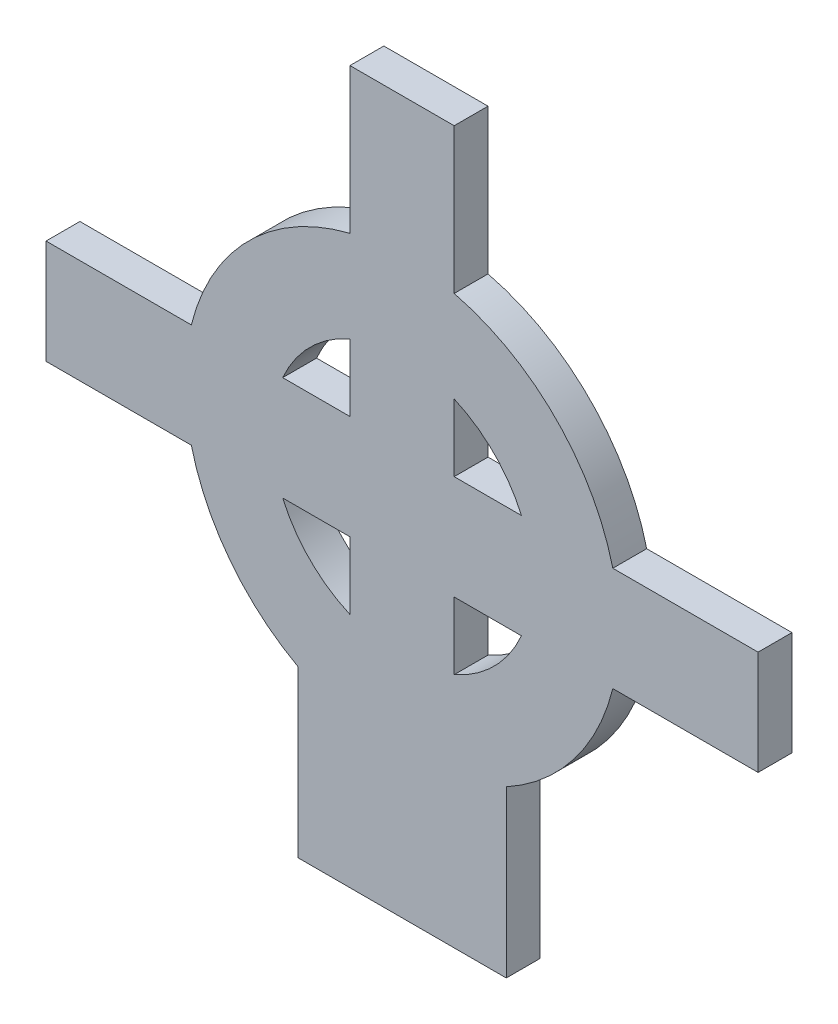
from build123d import *

# Parameters (mm, degrees)
SALIENTE_EXTRUIR1_DEPTH = 1.95
CROQUIS2_W              = 9.2
CROQUIS2_H              = 12
CORTAR_EXTRUIR1_DEPTH   = 2


with BuildPart() as part:
    # Croquis1 → Saliente-Extruir1 (new body)
    with BuildSketch(Plane.XY):
        with BuildLine():
            Line((0, 0), (-12, 0))
            Line((-12, 0), (-12, 9.5341439))
            ThreePointArc((-12, 9.5341439), (-15.903544777, 12.873087069), (-18.1346611, 17.5))
            Line((-18.1346611, 17.5), (-26.5, 17.5))
            Line((-26.5, 17.5), (-26.5, 23.5))
            Line((-26.5, 23.5), (-18.1346611, 23.5))
            ThreePointArc((-18.1346611, 23.5), (-14.838834765, 29.338834765), (-9, 32.6346611))
            Line((-9, 32.6346611), (-9, 41))
            Line((-9, 41), (-3, 41))
            Line((-3, 41), (-3, 32.6346611))
            ThreePointArc((-3, 32.6346611), (2.838834765, 29.338834765), (6.1346611, 23.5))
            Line((6.1346611, 23.5), (14.5, 23.5))
            Line((14.5, 23.5), (14.5, 17.5))
            Line((14.5, 17.5), (6.1346611, 17.5))
            ThreePointArc((6.1346611, 17.5), (3.903544777, 12.873087069), (0, 9.5341439))
            Line((0, 9.5341439), (0, 0))
        make_face()
        with BuildLine():
            Line((-9, 23.5), (-9, 27.373863542))
            ThreePointArc((-9, 27.373863542), (-11.303300859, 25.803300859), (-12.873863542, 23.5))
            Line((-12.873863542, 23.5), (-9, 23.5))
        make_face(mode=Mode.SUBTRACT)
        with BuildLine():
            Line((-3, 23.5), (-3, 27.373863542))
            ThreePointArc((-3, 27.373863542), (-0.696699141, 25.803300859), (0.873863542, 23.5))
            Line((0.873863542, 23.5), (-3, 23.5))
        make_face(mode=Mode.SUBTRACT)
        with BuildLine():
            Line((-9, 17.5), (-9, 13.626136458))
            ThreePointArc((-9, 13.626136458), (-11.303300859, 15.196699141), (-12.873863542, 17.5))
            Line((-12.873863542, 17.5), (-9, 17.5))
        make_face(mode=Mode.SUBTRACT)
        with BuildLine():
            Line((-3, 17.5), (-3, 13.626136458))
            ThreePointArc((-3, 13.626136458), (-0.696699141, 15.196699141), (0.873863542, 17.5))
            Line((0.873863542, 17.5), (-3, 17.5))
        make_face(mode=Mode.SUBTRACT)
    extrude(amount=SALIENTE_EXTRUIR1_DEPTH)

    # Croquis2 → Cortar-Extruir1 (cut)
    with BuildSketch(Plane.XY.offset(4)):
        with Locations((-6, 6)):
            Rectangle(CROQUIS2_W, CROQUIS2_H)
    extrude(amount=-CORTAR_EXTRUIR1_DEPTH, mode=Mode.SUBTRACT)


solid = part.part
